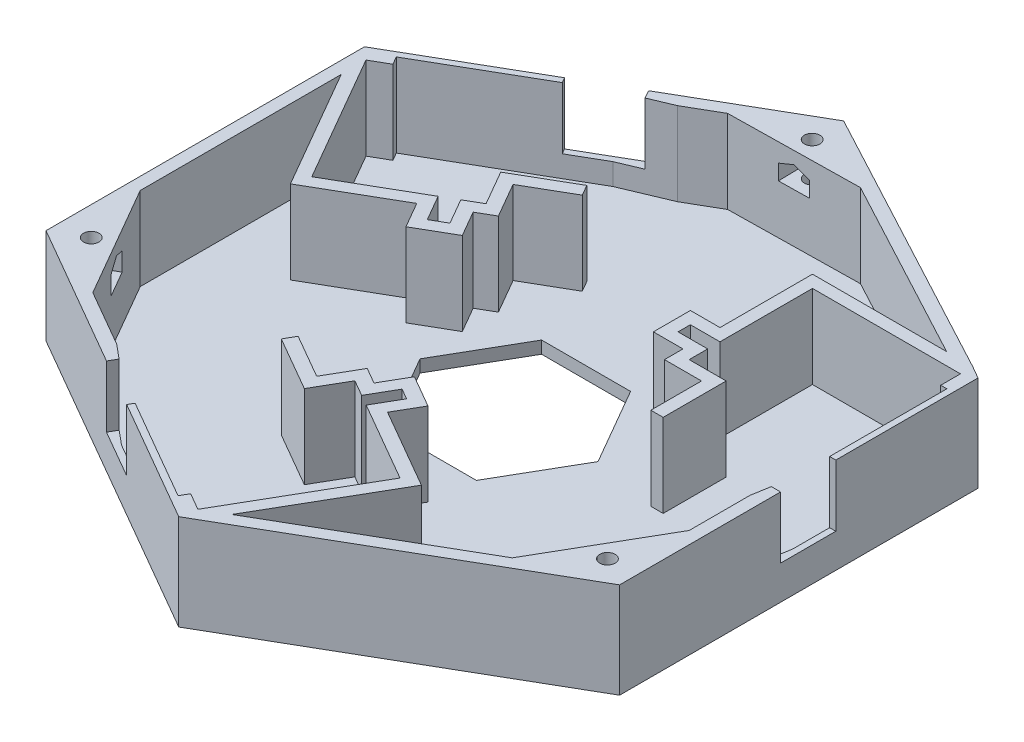
from build123d import *

# Parameters (mm, degrees)
BOSS_EXTRUDE1_DEPTH = 15.5
CUT_EXTRUDE1_DEPTH  = 24
CUT_EXTRUDE2_DEPTH  = 13.5
CUT_EXTRUDE3_DEPTH  = 13.5
CUT_EXTRUDE4_DEPTH  = 13.5
SKETCH6_R           = 1.15
CUT_EXTRUDE5_DEPTH  = 10.5
SKETCH8_W           = 5
SKETCH8_H           = 2
CUT_EXTRUDE7_DEPTH  = 5.5
SKETCH9_W           = 5
SKETCH9_H           = 2
CUT_EXTRUDE8_DEPTH  = 5.5
SKETCH10_W          = 5
SKETCH10_H          = 2
CUT_EXTRUDE9_DEPTH  = 5.5
CUT_EXTRUDE10_DEPTH = 20
BOSS_EXTRUDE2_DEPTH = 13.5
BOSS_EXTRUDE3_DEPTH = 13.5
SKETCH15_R          = 1.25
CUT_EXTRUDE11_DEPTH = 8.5
SKETCH19_W          = 17
SKETCH19_H          = 2
CUT_EXTRUDE15_DEPTH = 13.5
CUT_EXTRUDE16_DEPTH = 10
CUT_EXTRUDE17_DEPTH = 5.7
CUT_EXTRUDE18_DEPTH = 5.7
CUT_EXTRUDE19_DEPTH = 5.7


with BuildPart() as part:
    # Sketch1 → Boss-Extrude1 (new body)
    with BuildSketch(Plane(origin=(0, 0, 0), x_dir=(1, 0, 0), z_dir=(0, 1, 0))):
        Polygon((127, 0), (-63.5, 109.985226281), (-63.5, -109.985226281), align=None)
    extrude(amount=BOSS_EXTRUDE1_DEPTH)

    # Sketch2 → Cut-Extrude1 (cut)
    with BuildSketch(Plane(origin=(0, 15.5, 0), x_dir=(1, 0, 0), z_dir=(0, 1, 0))):
        Polygon((-63.5, -109.985226281), (16.5, -63.797204745), (-63.5, -17.60918321), align=None)
        Polygon((-63.5, 109.985226281), (16.5, 63.797204745), (-63.5, 17.60918321), align=None)
        Polygon((127, 0), (47, 46.188021535), (47, -46.188021535), align=None)
    extrude(amount=-CUT_EXTRUDE1_DEPTH, mode=Mode.SUBTRACT)

    # Sketch3 → Cut-Extrude2 (cut)
    with BuildSketch(Plane(origin=(0, 15.5, 0), x_dir=(1, 0, 0), z_dir=(0, 1, 0))):
        Polygon((21, 28.217265235), (21, 13.217265235), (16.2, 13.217265235), (16.2, 11.217265235), (21, 11.217265235), (21, 8.217265235), (27, 8.217265235), (27, 0), (45, 0), (46, 0), (46, 21.217265235), (46, 25.017265235), (45, 25.017265235), (45, 28.217265235), align=None)
        Polygon((14.186868519, -31.862153395), (1.196487462, -24.362153395), (3.596487462, -20.205231457), (1.864436654, -19.205231457), (-0.535563346, -23.362153395), (-3.133639557, -21.862153395), (-6.133639557, -27.058305818), (-13.25, -22.9496732), (-22.25, -38.538130468), (-23, -39.837168574), (-4.625309308, -50.445801192), (-1.334412773, -52.345801192), (-0.584412773, -51.046763086), (2.186868519, -52.646763086), align=None)
        Polygon((-35.28503876, 3.29953441), (-22.294657703, 10.79953441), (-19.894657703, 6.642612472), (-17.564436654, 7.987966222), (-19.964436654, 12.14488816), (-17.366360443, 13.64488816), (-20.616360443, 19.274053285), (-13.5, 23.382685902), (-22.5, 38.97114317), (-23, 39.837168574), (-41.374690692, 29.228535957), (-45.263757468, 26.983182207), (-44.513757468, 25.684144101), (-47.28503876, 24.084144101), align=None)
    extrude(amount=-CUT_EXTRUDE2_DEPTH, mode=Mode.SUBTRACT)

    # Sketch4 → Cut-Extrude3 (cut)
    with BuildSketch(Plane(origin=(0, 15.5, 0), x_dir=(1, 0, 0), z_dir=(0, 1, 0))):
        Polygon((3.668919326, -54.079775788), (16.5, -61.487803669), (35, -50.806823689), (45, -33.486315613), (45, -5.916079783), (46, 0), (44, 0), (44, -2), (25, -2), (25, 6.217265235), (19, 6.217265235), (19, 9.217265235), (14.2, 9.217265235), (14.2, 15.217265235), (19, 15.217265235), (19, 30.217265235), (45, 30.217265235), (45, 45.033320997), (26.5, 55.714300977), (6.5, 55.714300977), (-15.626136458, 42.939770137), (-23, 39.837168574), (-22, 38.105117767), (-20.267949192, 39.105117767), (-10.767949192, 22.650635095), (-17.884309636, 18.542002477), (-14.634309636, 12.912837353), (-17.232385847, 11.412837353), (-14.832385847, 7.255915414), (-20.626708511, 3.910561665), (-23.026708511, 8.067483603), (-36.017089568, 0.567483603), (-49.267089568, 23.517156803), (-61.5, 16.454482672), (-61.5, -4.907477288), (-51.5, -22.227985364), (-27.623475383, -36.013103279), (-23, -39.837168574), (-22, -38.105117767), (-23.732050808, -37.105117767), (-13.982050808, -20.217622393), (-6.865690364, -24.32625501), (-3.865690364, -19.130102587), (-1.267614153, -20.630102587), (1.132385847, -16.473180649), (6.32853827, -19.473180649), (3.92853827, -23.630102587), (16.918919326, -31.130102587), align=None)
    extrude(amount=-CUT_EXTRUDE3_DEPTH, mode=Mode.SUBTRACT)

    # Sketch5 → Cut-Extrude4 (cut)
    with BuildSketch(Plane(origin=(0, 2, 0), x_dir=(1, 0, 0), z_dir=(0, 1, 0))):
        Polygon((14.43375673, 0), (7.216878365, 12.5), (-7.216878365, 12.5), (-14.43375673, 0), (-7.216878365, -12.5), (7.216878365, -12.5), align=None)
    extrude(amount=-CUT_EXTRUDE4_DEPTH, mode=Mode.SUBTRACT)

    # Sketch6 → Cut-Extrude5 (cut)
    with BuildSketch(Plane(origin=(0, 15.5, 0), x_dir=(1, 0, 0), z_dir=(0, 1, 0))):
        with Locations((-59.125, -15.083275783)):
            Circle(SKETCH6_R)
        with Locations((16.5, 58.74538989)):
            Circle(SKETCH6_R)
        with Locations((42.625, -43.662114107)):
            Circle(SKETCH6_R)
    extrude(amount=-CUT_EXTRUDE5_DEPTH, mode=Mode.SUBTRACT)

    # Sketch8 → Cut-Extrude7 (cut)
    with BuildSketch(Plane(origin=(-48.25, 0, 27.857150488), x_dir=(-0.5, 0, -0.866025404), z_dir=(0.866025404, 0, -0.5))):
        with Locations((16.5, 5.1)):
            Rectangle(SKETCH8_W, SKETCH8_H)
    extrude(amount=-CUT_EXTRUDE7_DEPTH, mode=Mode.SUBTRACT)

    # Sketch9 → Cut-Extrude8 (cut)
    with BuildSketch(Plane(origin=(48.25, 0, 27.857150488), x_dir=(-0.5, 0, 0.866025404), z_dir=(-0.866025404, 0, -0.5))):
        with Locations((16.5, 5.1)):
            Rectangle(SKETCH9_W, SKETCH9_H)
    extrude(amount=-CUT_EXTRUDE8_DEPTH, mode=Mode.SUBTRACT)

    # Sketch10 → Cut-Extrude9 (cut)
    with BuildSketch(Plane.XY.offset(-55.714300977)):
        with Locations((16.5, 5.1)):
            Rectangle(SKETCH10_W, SKETCH10_H)
    extrude(amount=-CUT_EXTRUDE9_DEPTH, mode=Mode.SUBTRACT)

    # Sketch12 → Cut-Extrude10 (cut)
    with BuildSketch(Plane(origin=(0, 15.5, 0), x_dir=(1, 0, 0), z_dir=(0, 1, 0))):
        Polygon((-49.267089568, 23.517156803), (-49.267089568, -25.82655788), (-63.5, -17.60918321), (-63.5, 17.60918321), (-49.267089568, 25.82655788), align=None)
        Polygon((3.668919326, -54.079775788), (47, -29.062564697), (47, -46.188021535), (16.5, -63.797204745), (1.668919326, -55.234476326), align=None)
        Polygon((45, 30.217265235), (0, 54.270925304), (16.5, 63.797204745), (47, 46.188021535), (47, 29.062564697), align=None)
    extrude(amount=-CUT_EXTRUDE10_DEPTH, mode=Mode.SUBTRACT)

    # Sketch13 → Boss-Extrude2 (add)
    with BuildSketch(Plane(origin=(0, 2, 0), x_dir=(1, 0, 0), z_dir=(0, 1, 0))):
        Polygon((-49.267089568, -23.517156803), (-49.267089568, 23.517156803), (-47.267089568, 20.053055188), (-47.267089568, -24.671857341), align=None)
        Polygon((45, -30.217265235), (3.668919326, -54.079775788), (5.668919326, -50.615674173), (45, -27.907864158), align=None)
        Polygon((45, 30.217265235), (2.07703105, 53.160698663), (0.037424254, 51.98313113), (40.757379657, 30.217265235), align=None)
    extrude(amount=BOSS_EXTRUDE2_DEPTH)

    # Sketch14 → Boss-Extrude3 (add)
    with BuildSketch(Plane(origin=(0, 2, 0), x_dir=(1, 0, 0), z_dir=(0, 1, 0))):
        Polygon((-47.267089568, -24.671857341), (-36.767089568, -30.734035168), (-47.267089568, -12.547501688), align=None)
        Polygon((0.037424254, 51.98313113), (-10.462575746, 45.920953304), (10.730086226, 46.267627657), align=None)
        Polygon((45, -27.907864158), (45, -15.783508505), (34.5, -33.970041985), align=None)
    extrude(amount=BOSS_EXTRUDE3_DEPTH)

    # Sketch15 → Cut-Extrude11 (cut)
    with BuildSketch(Plane(origin=(0, 15.5, 0), x_dir=(1, 0, 0), z_dir=(0, 1, 0))):
        with Locations((-44.615165779, -23.140768428)):
            Circle(SKETCH15_R)
        with Locations((42.348076211, -26.376775245)):
            Circle(SKETCH15_R)
        with Locations((0.06687762, 49.09429048)):
            Circle(SKETCH15_R)
    extrude(amount=-CUT_EXTRUDE11_DEPTH, mode=Mode.SUBTRACT)

    # Sketch19 → Cut-Extrude15 (cut)
    with BuildSketch(Plane(origin=(0, 15.5, 0), x_dir=(1, 0, 0), z_dir=(0, 1, 0))):
        Polygon((-13.25, -22.9496732), (-22, -38.105117767), (-23.732050808, -37.105117767), (-14.982050808, -21.9496732), align=None)
        Polygon((-13.5, 23.382685902), (-22, 38.105117767), (-20.267949192, 39.105117767), (-11.767949192, 24.382685902), align=None)
        with Locations((35.5, -1)):
            Rectangle(SKETCH19_W, SKETCH19_H)
    extrude(amount=-CUT_EXTRUDE15_DEPTH, mode=Mode.SUBTRACT)

    # Sketch20 → Cut-Extrude16 (cut)
    with BuildSketch(Plane(origin=(0, 15.5, 0), x_dir=(1, 0, 0), z_dir=(0, 1, 0))):
        Polygon((46, 0), (45.5, -2.958039892), (47, -2.958039892), (47, 0), (47, 6), (46, 6), align=None)
        Polygon((-23, 39.837168574), (-28.196152423, 36.837168574), (-28.696152423, 37.703193978), (-23.5, 40.703193978), (-20.063068229, 42.687507461), (-19.313068229, 41.388469355), align=None)
        Polygon((-23, -39.837168574), (-17.803847577, -42.837168574), (-18.303847577, -43.703193978), (-23.5, -40.703193978), (-26.061737691, -39.224174032), (-25.311737691, -37.925135926), align=None)
    extrude(amount=-CUT_EXTRUDE16_DEPTH, mode=Mode.SUBTRACT)

    # Sketch16 → Cut-Extrude17 (cut)
    with BuildSketch(Plane(origin=(-0.753783321, 0, -46.079771924), x_dir=(0.999866231, 0, -0.016356038), z_dir=(0.016356038, 0, 0.999866231))):
        Polygon((-1.612342698, 12.5), (0.887657302, 13.5), (3.387657302, 12.5), (3.387657302, 10), (-1.612342698, 10), align=None)
    extrude(amount=-CUT_EXTRUDE17_DEPTH, mode=Mode.SUBTRACT)

    # Sketch17 → Cut-Extrude18 (cut)
    with BuildSketch(Plane(origin=(-40.883544784, 0, 23.604125586), x_dir=(-0.5, 0, -0.866025404), z_dir=(0.866025404, 0, -0.5))):
        Polygon((-0.232910432, 12.5), (-0.232910432, 9.5), (4.767089568, 9.5), (4.767089568, 12.5), (2.267089568, 13.5), align=None)
    extrude(amount=-CUT_EXTRUDE18_DEPTH, mode=Mode.SUBTRACT)

    # Sketch18 → Cut-Extrude19 (cut)
    with BuildSketch(Plane(origin=(40.584459663, 0, 23.431448711), x_dir=(-0.5, 0, 0.866025404), z_dir=(-0.866025404, 0, -0.5))):
        Polygon((-0.831080674, 12.5), (-0.831080674, 9.5), (4.168919326, 9.5), (4.168919326, 12.5), (1.668919326, 13.5), align=None)
    extrude(amount=-CUT_EXTRUDE19_DEPTH, mode=Mode.SUBTRACT)


solid = part.part
